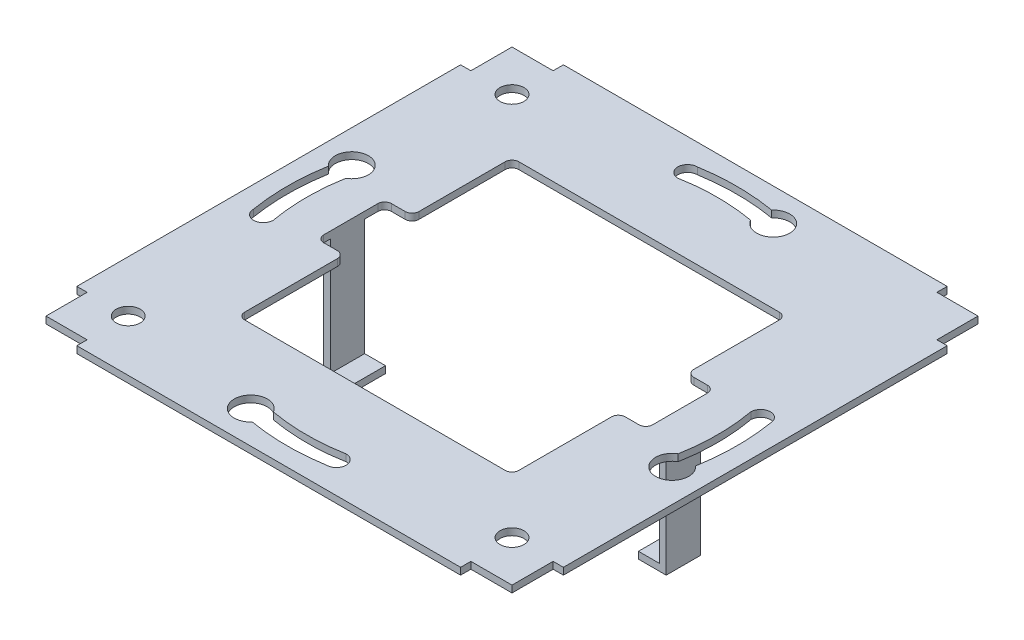
from build123d import *

# Parameters (mm, degrees)
SKETCH_2_R      = 1.75
EXTRUDE_1_DEPTH = 1
EXTRUDE_2_DEPTH = 2.5


with BuildPart() as part:
    # Эскиз2 → Бобышка-Вытянуть1 (new body)
    with BuildSketch(Plane(origin=(0, 0, 0), x_dir=(1, 0, 0), z_dir=(0, 1, 0))):
        Polygon((-35.5, 28), (-35.5, -28), (-34, -28), (-34, -34), (-28, -34), (-28, -35.5), (28, -35.5), (28, -34), (34, -34), (34, -28), (35.5, -28), (35.5, 28), (34, 28), (34, 34), (28, 34), (28, 35.5), (-28, 35.5), (-28, 34), (-34, 34), (-34, 28), align=None)
        with Locations((28, -28)):
            Circle(SKETCH_2_R, mode=Mode.SUBTRACT)
        with Locations((-28, -28)):
            Circle(SKETCH_2_R, mode=Mode.SUBTRACT)
        with Locations((-28, 28)):
            Circle(SKETCH_2_R, mode=Mode.SUBTRACT)
        with BuildLine():
            Line((20, 19), (20, 6.525504327))
            ThreePointArc((20, 6.525504327), (20.292893219, 5.818397545), (21, 5.525504327))
            Line((21, 5.525504327), (23, 5.525504327))
            ThreePointArc((23, 5.525504327), (23.707106781, 5.232611108), (24, 4.525504327))
            Line((24, 4.525504327), (24, -3.474495673))
            ThreePointArc((24, -3.474495673), (23.707106781, -4.181602455), (23, -4.474495673))
            Line((23, -4.474495673), (21, -4.474495673))
            ThreePointArc((21, -4.474495673), (20.292893219, -4.767388892), (20, -5.474495673))
            Line((20, -5.474495673), (20, -19))
            ThreePointArc((20, -19), (19.707106781, -19.707106781), (19, -20))
            Line((19, -20), (-19, -20))
            ThreePointArc((-19, -20), (-19.707106781, -19.707106781), (-20, -19))
            Line((-20, -19), (-20, -5.474495673))
            ThreePointArc((-20, -5.474495673), (-20.292893219, -4.767388892), (-21, -4.474495673))
            Line((-21, -4.474495673), (-23, -4.474495673))
            ThreePointArc((-23, -4.474495673), (-23.707106781, -4.181602455), (-24, -3.474495673))
            Line((-24, -3.474495673), (-24, 4.418145483))
            ThreePointArc((-24, 4.418145483), (-23.707106781, 5.125252264), (-23, 5.418145483))
            Line((-23, 5.418145483), (-21, 5.418145483))
            ThreePointArc((-21, 5.418145483), (-20.292893219, 5.711038701), (-20, 6.418145483))
            Line((-20, 6.418145483), (-20, 19))
            ThreePointArc((-20, 19), (-19.707106781, 19.707106781), (-19, 20))
            Line((-19, 20), (19, 20))
            ThreePointArc((19, 20), (19.707106781, 19.707106781), (20, 19))
        make_face(mode=Mode.SUBTRACT)
        with BuildLine():
            ThreePointArc((-32.375246916, -5.328874762), (-32.81067753, 0.113838264), (-32.337490331, 5.553398796))
            ThreePointArc((-32.337490331, 5.553398796), (-30.509920838, 9.7779661), (-29.531671369, 5.280188077))
            ThreePointArc((-29.531671369, 5.280188077), (-29.999989805, -0.024733046), (-29.522924885, -5.328874762))
            ThreePointArc((-29.522924885, -5.328874762), (-30.949085901, -6.755035778), (-32.375246916, -5.328874762))
        make_face(mode=Mode.SUBTRACT)
        with BuildLine():
            ThreePointArc((5.553398796, 32.337490331), (9.7779661, 30.509920838), (5.280188077, 29.531671369))
            ThreePointArc((5.280188077, 29.531671369), (-0.024733046, 29.999989805), (-5.328874762, 29.522924885))
            ThreePointArc((-5.328874762, 29.522924885), (-6.755035778, 30.949085901), (-5.328874762, 32.375246916))
            ThreePointArc((-5.328874762, 32.375246916), (0.113838264, 32.81067753), (5.553398796, 32.337490331))
        make_face(mode=Mode.SUBTRACT)
        with BuildLine():
            ThreePointArc((32.337490331, -5.553398796), (30.509920838, -9.7779661), (29.531671369, -5.280188077))
            ThreePointArc((29.531671369, -5.280188077), (29.999989805, 0.024733046), (29.522924885, 5.328874762))
            ThreePointArc((29.522924885, 5.328874762), (30.949085901, 6.755035778), (32.375246916, 5.328874762))
            ThreePointArc((32.375246916, 5.328874762), (32.81067753, -0.113838264), (32.337490331, -5.553398796))
        make_face(mode=Mode.SUBTRACT)
        with BuildLine():
            ThreePointArc((-5.553398796, -32.337490331), (-9.7779661, -30.509920838), (-5.280188077, -29.531671369))
            ThreePointArc((-5.280188077, -29.531671369), (0.024733046, -29.999989805), (5.328874762, -29.522924885))
            ThreePointArc((5.328874762, -29.522924885), (6.755035778, -30.949085901), (5.328874762, -32.375246916))
            ThreePointArc((5.328874762, -32.375246916), (-0.113838264, -32.81067753), (-5.553398796, -32.337490331))
        make_face(mode=Mode.SUBTRACT)
    extrude(amount=EXTRUDE_1_DEPTH)

    # Эскиз3 → Бобышка-Вытянуть2 (add, symmetric)
    with BuildSketch(Plane.XY):
        Polygon((-25, 0), (-24, 0), (-24, -17), (-20.953427174, -17), (-20.953427174, -18), (-25, -18), align=None)
        Polygon((25, 0), (25, -18), (20.953427174, -18), (20.953427174, -17), (24, -17), (24, 0), align=None)
    extrude(amount=EXTRUDE_2_DEPTH, both=True)


solid = part.part
